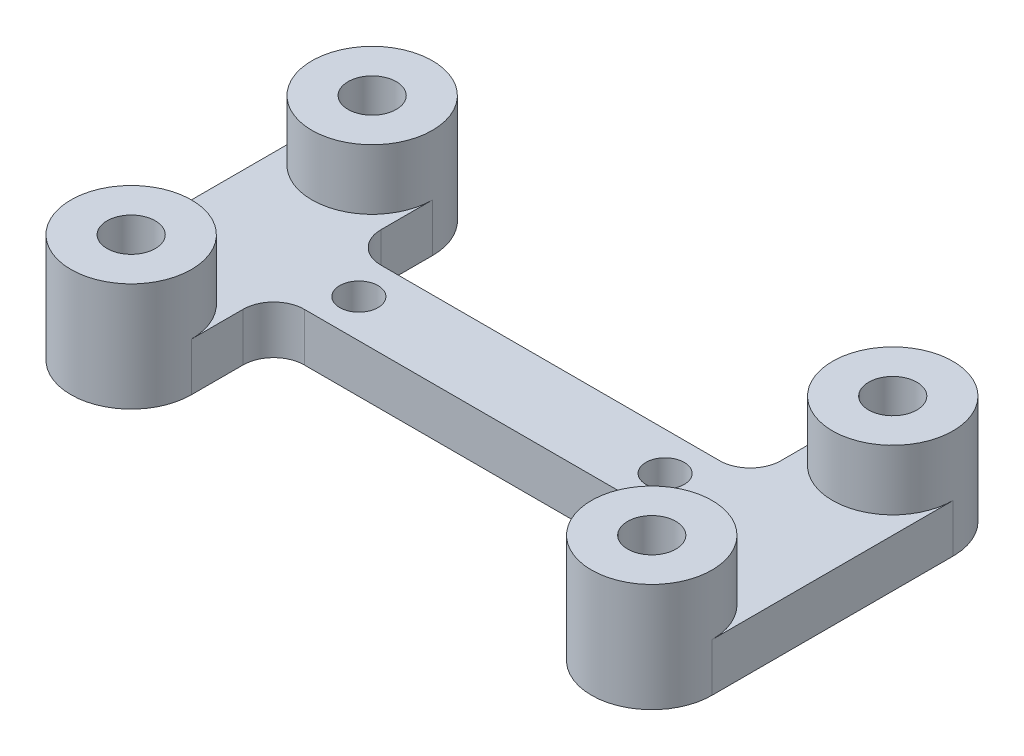
from build123d import *

# Parameters (mm, degrees)
SKETCH4_R             = 5
SKETCH4_R_2           = 2
BOSS_EXTRUDE3_DEPTH   = 9
BOSS_EXTRUDE3_2_DEPTH = 9
BOSS_EXTRUDE3_3_DEPTH = 9
BOSS_EXTRUDE3_4_DEPTH = 9
BOSS_EXTRUDE4_DEPTH   = 4
SKETCH6_R             = 1.5875
CUT_EXTRUDE1_DEPTH    = 5
FILLET1_R             = 2.54


with BuildPart() as part:
    # Sketch4 → Boss-Extrude3 (new body)
    with BuildSketch(Plane(origin=(0, 0, 0), x_dir=(1, 0, 0), z_dir=(0, 1, 0))):
        with Locations((-21.59, 9.9949)):
            Circle(SKETCH4_R)
        with Locations((-21.59, 9.9949)):
            Circle(SKETCH4_R_2, mode=Mode.SUBTRACT)
    extrude(amount=BOSS_EXTRUDE3_DEPTH)



with BuildPart() as body_2:
    # Sketch4 → Boss-Extrude3 2 (new body)
    with BuildSketch(Plane(origin=(0, 0, 0), x_dir=(1, 0, 0), z_dir=(0, 1, 0))):
        with Locations((-21.59, -9.9949)):
            Circle(SKETCH4_R)
        with Locations((-21.59, -9.9949)):
            Circle(SKETCH4_R_2, mode=Mode.SUBTRACT)
    extrude(amount=BOSS_EXTRUDE3_2_DEPTH)


with BuildPart() as body_3:
    # Sketch4 → Boss-Extrude3 3 (new body)
    with BuildSketch(Plane(origin=(0, 0, 0), x_dir=(1, 0, 0), z_dir=(0, 1, 0))):
        with Locations((21.59, 9.9949)):
            Circle(SKETCH4_R)
        with Locations((21.59, 9.9949)):
            Circle(SKETCH4_R_2, mode=Mode.SUBTRACT)
    extrude(amount=BOSS_EXTRUDE3_3_DEPTH)


with BuildPart() as body_4:
    # Sketch4 → Boss-Extrude3 4 (new body)
    with BuildSketch(Plane(origin=(0, 0, 0), x_dir=(1, 0, 0), z_dir=(0, 1, 0))):
        with Locations((21.59, -9.9949)):
            Circle(SKETCH4_R)
        with Locations((21.59, -9.9949)):
            Circle(SKETCH4_R_2, mode=Mode.SUBTRACT)
    extrude(amount=BOSS_EXTRUDE3_4_DEPTH)


with BuildPart() as part_1:
    add(part.part)

    add(body_2.part)  # Boss-Extrude4 merges body 2
    # Sketch5 → Boss-Extrude4 (add)
    with BuildSketch(Plane(origin=(0, 0, 0), x_dir=(1, 0, 0), z_dir=(0, 1, 0))):
        with BuildLine():
            ThreePointArc((-23.59, -9.9949), (-21.59, -7.9949), (-19.59, -9.9949))
            Line((-19.59, -9.9949), (-16.59, -9.9949))
            Line((-16.59, -9.9949), (-16.59, -3.175))
            Line((-16.59, -3.175), (0, -3.175))
            Line((0, -3.175), (0, 3.175))
            Line((0, 3.175), (-16.59, 3.175))
            Line((-16.59, 3.175), (-16.59, 9.9949))
            Line((-16.59, 9.9949), (-19.59, 9.9949))
            ThreePointArc((-19.59, 9.9949), (-21.59, 7.9949), (-23.59, 9.9949))
            Line((-23.59, 9.9949), (-26.59, 9.9949))
            Line((-26.59, 9.9949), (-26.59, -9.9949))
            Line((-26.59, -9.9949), (-23.59, -9.9949))
        make_face()
    boss_extrude4 = extrude(amount=BOSS_EXTRUDE4_DEPTH)

    # Mirror1: Boss-Extrude4 across plane
    add(boss_extrude4.mirror(Plane(origin=(0, 0, 0), x_dir=(0, 0, 1), z_dir=(1, 0, 0))))

    # Sketch6 → Cut-Extrude1 (cut, through all)
    with BuildSketch(Plane(origin=(0, 4, 0), x_dir=(1, 0, 0), z_dir=(0, 1, 0))):
        with Locations((-12.7, 0)):
            Circle(SKETCH6_R)
        with Locations((12.7, 0)):
            Circle(SKETCH6_R)
    extrude(amount=-CUT_EXTRUDE1_DEPTH, mode=Mode.SUBTRACT)

    # Fillet1
    fillet1_edges = [part_1.edges().sort_by_distance(p)[0] for p in [
        (-16.59, 2, 3.175),
        (-16.59, 2, -3.175),
        (16.59, 2, -3.175),
        (16.59, 2, 3.175),
    ]]
    fillet(fillet1_edges, radius=FILLET1_R)


solid = Compound([body_3.part, body_4.part, part_1.part])
